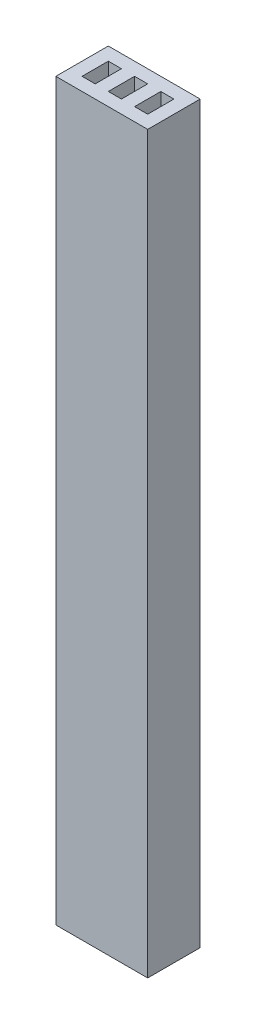
from build123d import *

# Parameters (mm, degrees)
SKETCH1_W           = 7
SKETCH1_H           = 4
SKETCH1_W_2         = 1
SKETCH1_H_2         = 2
BOSS_EXTRUDE1_DEPTH = 56


with BuildPart() as part:
    # Sketch1 → Boss-Extrude1 (new body)
    with BuildSketch(Plane(origin=(0, 0, 0), x_dir=(1, 0, 0), z_dir=(0, 1, 0))):
        with Locations((-3.316052228, -2.763376857)):
            Rectangle(SKETCH1_W, SKETCH1_H)
        with Locations((-5.316052228, -2.763376857)):
            Rectangle(SKETCH1_W_2, SKETCH1_H_2, mode=Mode.SUBTRACT)
        with Locations((-3.316052228, -2.763376857)):
            Rectangle(SKETCH1_W_2, SKETCH1_H_2, mode=Mode.SUBTRACT)
        with Locations((-1.316052228, -2.763376857)):
            Rectangle(SKETCH1_W_2, SKETCH1_H_2, mode=Mode.SUBTRACT)
    extrude(amount=BOSS_EXTRUDE1_DEPTH)


solid = part.part
